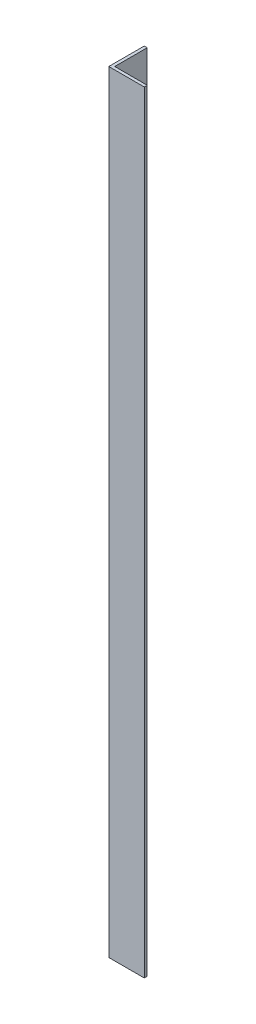
from build123d import *

# Parameters (mm, degrees)
BOSS_EXTRUDE1_DEPTH = 414.3375


with BuildPart() as part:
    # Sketch1 → Boss-Extrude1 (new body)
    with BuildSketch(Plane(origin=(0, 0, 0), x_dir=(1, 0, 0), z_dir=(0, 1, 0))):
        Polygon((0, 0), (19.05, 0), (19.05, 1.5875), (1.5875, 1.5875), (1.5875, 19.05), (0, 19.05), align=None)
    extrude(amount=BOSS_EXTRUDE1_DEPTH)


solid = part.part
